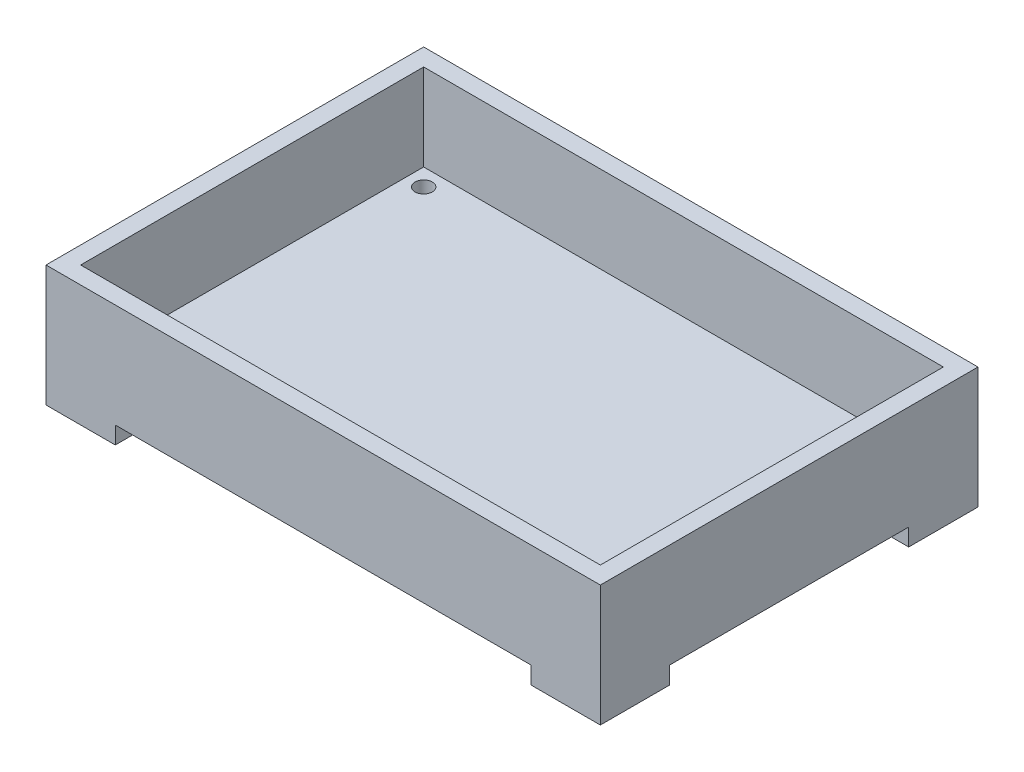
from build123d import *

# Parameters (mm, degrees)
SKETCH1_W               = 203.2
SKETCH1_H               = 138.43
BOSS_EXTRUDE2_DEPTH     = 38.1
SHELL1_T                = -6.35
SKETCH2_W               = 25.4
SKETCH2_H               = 25.4
BOSS_EXTRUDE4_DEPTH     = 6.35
SKETCH3_R               = 3.175
CUT_EXTRUDE1_DEPTH      = 13.7
MIRROR4_COPY_1_SKETCH_W = 25.4
MIRROR4_COPY_1_SKETCH_H = 25.4
MIRROR4_COPY_1_DEPTH    = 6.35
MIRROR4_COPY_2_SKETCH_R = 3.175
MIRROR4_COPY_2_DEPTH    = 13.7


with BuildPart() as part:
    # Sketch1 → Boss-Extrude2 (new body)
    with BuildSketch(Plane(origin=(0, 0, 0), x_dir=(1, 0, 0), z_dir=(0, 1, 0))):
        Rectangle(SKETCH1_W, SKETCH1_H)
    extrude(amount=BOSS_EXTRUDE2_DEPTH)

    # Shell1
    shell1_openings = [part.faces().sort_by_distance(p)[0] for p in [
        (0, 38.1, 0),
    ]]
    offset(amount=SHELL1_T, openings=shell1_openings, kind=Kind.INTERSECTION)

    # Sketch2 → Boss-Extrude4 (add)
    with BuildSketch(Plane.XZ):
        with Locations((-88.9, 56.515)):
            Rectangle(SKETCH2_W, SKETCH2_H)
    boss_extrude4 = extrude(amount=BOSS_EXTRUDE4_DEPTH)

    # Sketch3 → Cut-Extrude1 (cut, through all)
    with BuildSketch(Plane(origin=(0, 6.35, 0), x_dir=(1, 0, 0), z_dir=(0, 1, 0))):
        with Locations((-88.9, -56.515)):
            Circle(SKETCH3_R)
    cut_extrude1 = extrude(amount=-CUT_EXTRUDE1_DEPTH, mode=Mode.SUBTRACT)

    # Mirror3: Boss-Extrude4, Cut-Extrude1 across plane
    add(boss_extrude4.mirror(Plane(origin=(0, 0, 0), x_dir=(0, 0, 1), z_dir=(1, 0, 0))))
    add(cut_extrude1.mirror(Plane(origin=(0, 0, 0), x_dir=(0, 0, 1), z_dir=(1, 0, 0))), mode=Mode.SUBTRACT)

    # Mirror4: Boss-Extrude4, Cut-Extrude1 across plane
    add(boss_extrude4.mirror(Plane.XY))
    add(cut_extrude1.mirror(Plane.XY), mode=Mode.SUBTRACT)

    # Mirror4 copy 1 sketch → Mirror4 copy 1 (add)
    with BuildSketch(Plane(origin=(0, 0, 0), x_dir=(-1, 0, 0), z_dir=(0, -1, 0))):
        with Locations((-88.9, 56.515)):
            Rectangle(MIRROR4_COPY_1_SKETCH_W, MIRROR4_COPY_1_SKETCH_H)
    extrude(amount=MIRROR4_COPY_1_DEPTH)

    # Mirror4 copy 2 sketch → Mirror4 copy 2 (cut, through all)
    with BuildSketch(Plane(origin=(0, 6.35, 0), x_dir=(-1, 0, 0), z_dir=(0, 1, 0))):
        with Locations((-88.9, -56.515)):
            Circle(MIRROR4_COPY_2_SKETCH_R)
    extrude(amount=-MIRROR4_COPY_2_DEPTH, mode=Mode.SUBTRACT)


solid = part.part
